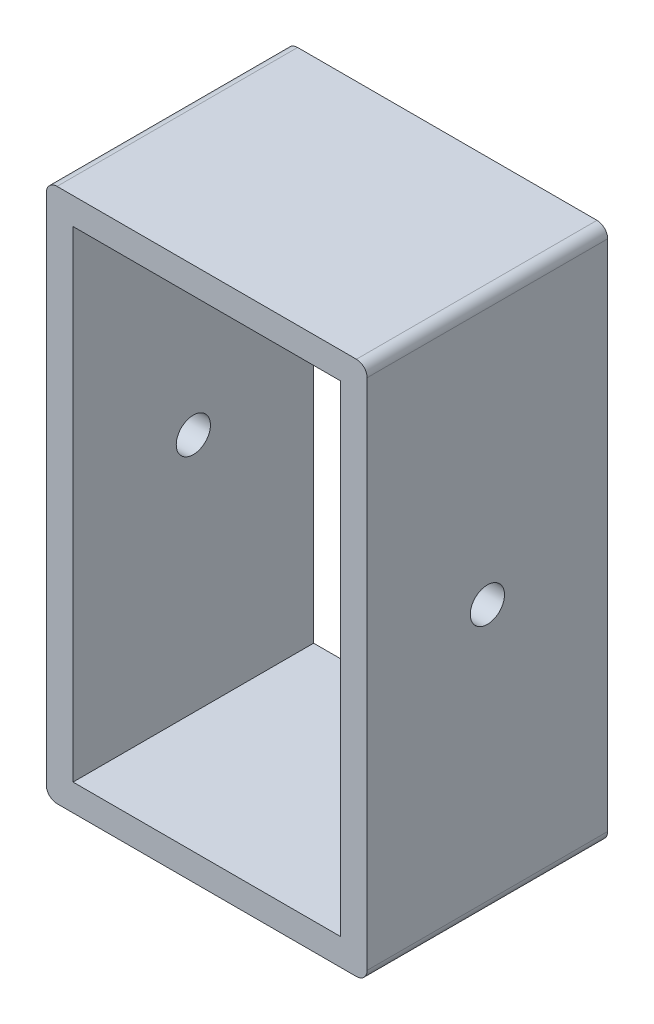
from build123d import *

# Parameters (mm, degrees)
SKETCH1_W           = 22.5
SKETCH1_H           = 45
BOSS_EXTRUDE1_DEPTH = 2.5
SKETCH2_W           = 27.5
SKETCH2_H           = 22.5
BOSS_EXTRUDE2_DEPTH = 2.5
SKETCH3_W           = 27.5
SKETCH3_H           = 22.5
BOSS_EXTRUDE3_DEPTH = 2.5
SKETCH4_W           = 22.5
SKETCH4_H           = 50
BOSS_EXTRUDE4_DEPTH = 2.5
SKETCH5_R           = 1.6
CUT_EXTRUDE1_DEPTH  = 30
FILLET2_R           = 1
FILLET3_R           = 1


with BuildPart() as part:
    # Sketch1 → Boss-Extrude1 (new body)
    with BuildSketch(Plane(origin=(0, 0, 0), x_dir=(0, 0, -1), z_dir=(1, 0, 0))):
        Rectangle(SKETCH1_W, SKETCH1_H)
    extrude(amount=BOSS_EXTRUDE1_DEPTH)

    # Sketch2 → Boss-Extrude2 (add)
    with BuildSketch(Plane(origin=(0, -22.5, 0), x_dir=(-1, 0, 0), z_dir=(0, -1, 0))):
        with Locations((11.25, 0)):
            Rectangle(SKETCH2_W, SKETCH2_H)
    extrude(amount=BOSS_EXTRUDE2_DEPTH)

    # Sketch3 → Boss-Extrude3 (add)
    with BuildSketch(Plane(origin=(0, 22.5, 0), x_dir=(1, 0, 0), z_dir=(0, 1, 0))):
        with Locations((-11.25, 0)):
            Rectangle(SKETCH3_W, SKETCH3_H)
    extrude(amount=BOSS_EXTRUDE3_DEPTH)

    # Sketch4 → Boss-Extrude4 (add)
    with BuildSketch(Plane.ZY.offset(25)):
        Rectangle(SKETCH4_W, SKETCH4_H)
    extrude(amount=BOSS_EXTRUDE4_DEPTH)

    # Sketch5 → Cut-Extrude1 (cut)
    with BuildSketch(Plane.ZY.offset(27.5)):
        Circle(SKETCH5_R)
    extrude(amount=-CUT_EXTRUDE1_DEPTH, mode=Mode.SUBTRACT)

    # Fillet2
    fillet2_edges = [part.edges().sort_by_distance(p)[0] for p in [
        (2.5, 25, 0),
        (-27.5, 25, 0),
    ]]
    fillet(fillet2_edges, radius=FILLET2_R)

    # Fillet3
    fillet3_edges = [part.edges().sort_by_distance(p)[0] for p in [
        (2.5, -25, 0),
        (-27.5, -25, 0),
    ]]
    fillet(fillet3_edges, radius=FILLET3_R)


solid = part.part
